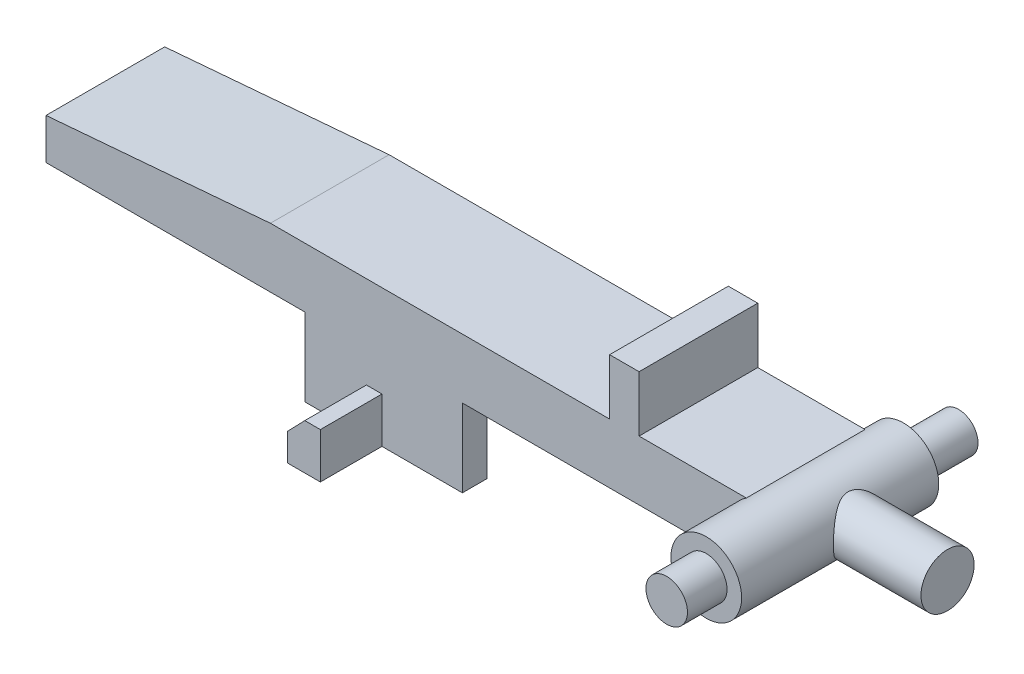
from build123d import *

# Parameters (mm, degrees)
BOSS_EXTRUDE1_DEPTH  = 9.15
SKETCH4_W            = 52.35
SKETCH4_H            = 5.35
CUT_EXTRUDE2_DEPTH   = 3
SKETCH6_R            = 2.725
BOSS_EXTRUDE2_DEPTH  = 13.65
SKETCH8_R            = 1.5
BOSS_EXTRUDE3_DEPTH  = 8.75
SKETCH9_R            = 1.6
BOSS_EXTRUDE4_DEPTH  = 4.6
SKETCH10_R           = 2.6
SKETCH10_R_2         = 0.925
BOSS_EXTRUDE5_DEPTH  = 7.55
SKETCH11_W           = 12.15
SKETCH11_H           = 6
BOSS_EXTRUDE6_DEPTH  = 1.9
BOSS_EXTRUDE7_DEPTH  = 4.75
SKETCH13_R           = 2.05
BOSS_EXTRUDE8_DEPTH  = 9.425
FILLET1_R            = 0.5
BOSS_EXTRUDE9_DEPTH  = 9.15
SKETCH20_R           = 2.725
BOSS_EXTRUDE10_DEPTH = 1.55
SKETCH21_R           = 1.5
CUT_EXTRUDE3_DEPTH   = 3


with BuildPart() as part:
    # Sketch1 → Boss-Extrude1 (new body)
    with BuildSketch(Plane.XY):
        Polygon((0, 0), (54.25, 0), (54.25, 4.6), (44.52, 4.6), (44.52, 8.9), (42.25, 8.9), (42.25, 4.6), (16.1, 4.6), (0, 3.25), align=None)
    extrude(amount=-BOSS_EXTRUDE1_DEPTH)

    # Sketch4 → Cut-Extrude2 (cut)
    with BuildSketch(Plane.XZ):
        with Locations((28.075, -4.575)):
            Rectangle(SKETCH4_W, SKETCH4_H)
    extrude(amount=-CUT_EXTRUDE2_DEPTH, mode=Mode.SUBTRACT)

    # Sketch6 → Boss-Extrude2 (add)
    with BuildSketch(Plane(origin=(0, 0, -10.65), x_dir=(-1, 0, 0), z_dir=(0, 0, -1))):
        with Locations((-54.25, 2.3)):
            Circle(SKETCH6_R)
    extrude(amount=-BOSS_EXTRUDE2_DEPTH)

    # Sketch8 → Boss-Extrude3 (add)
    with BuildSketch(Plane.XY.offset(-17.9)):
        with Locations((54.25, 2.3)):
            Circle(SKETCH8_R)
    extrude(amount=BOSS_EXTRUDE3_DEPTH)

    # Sketch9 → Boss-Extrude4 (add)
    with BuildSketch(Plane.XY.offset(3)):
        with Locations((54.25, 2.3)):
            Circle(SKETCH9_R)
    extrude(amount=BOSS_EXTRUDE4_DEPTH)

    # Sketch10 → Boss-Extrude5 (add)
    with BuildSketch(Plane.XZ.offset(-3)):
        with Locations((20.95, -5.325)):
            Circle(SKETCH10_R)
        with Locations((20.95, -5.325)):
            Circle(SKETCH10_R_2, mode=Mode.SUBTRACT)
    extrude(amount=BOSS_EXTRUDE5_DEPTH)

    # Sketch11 → Boss-Extrude6 (add)
    with BuildSketch(Plane.XY):
        with Locations((24.825, -3)):
            Rectangle(SKETCH11_W, SKETCH11_H)
    extrude(amount=-BOSS_EXTRUDE6_DEPTH)

    # Sketch12 → Boss-Extrude7 (add)
    with BuildSketch(Plane.XY):
        Polygon((24.7, -6), (24.7, -2.5), (23.5, -2.5), (22.15, -3.9), (22.15, -6), align=None)
    extrude(amount=BOSS_EXTRUDE7_DEPTH)

    # Sketch13 → Boss-Extrude8 (add)
    with BuildSketch(Plane(origin=(54.3, 0, 0), x_dir=(0, 0, -1), z_dir=(1, 0, 0))):
        with Locations((4.575, 2.3)):
            Circle(SKETCH13_R)
    extrude(amount=BOSS_EXTRUDE8_DEPTH)

    # Fillet1
    fillet1_edges = [part.edges().sort_by_distance(p)[0] for p in [
        (0, 1.625, 0),
        (0, 1.625, -9.15),
    ]]
    fillet(fillet1_edges, radius=FILLET1_R)

    # Sketch19 → Boss-Extrude9 (add)
    with BuildSketch(Plane.XY):
        Polygon((0.5, 0), (-1.2, 0), (-1.2, 3.149378882), (0.5, 3.291925466), align=None)
    extrude(amount=-BOSS_EXTRUDE9_DEPTH)

    # Sketch20 → Boss-Extrude10 (add)
    with BuildSketch(Plane.XY.offset(3)):
        with Locations((54.25, 2.3)):
            Circle(SKETCH20_R)
    extrude(amount=BOSS_EXTRUDE10_DEPTH)

    # Sketch21 → Cut-Extrude3 (cut)
    with BuildSketch(Plane(origin=(0, 0, -17.9), x_dir=(-1, 0, 0), z_dir=(0, 0, -1))):
        with Locations((-54.25, 2.3)):
            Circle(SKETCH21_R)
    extrude(amount=-CUT_EXTRUDE3_DEPTH, mode=Mode.SUBTRACT)


solid = part.part
